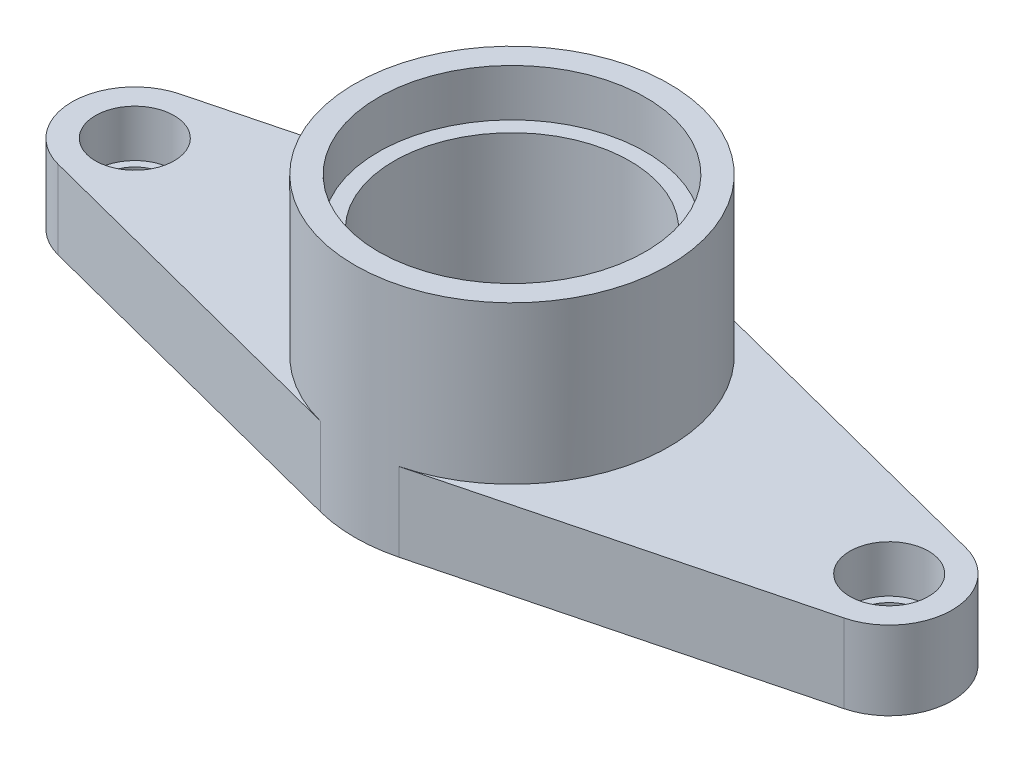
from build123d import *

# Parameters (mm, degrees)
BOSS_EXTRUDE3_DEPTH = 25
SKETCH3_R           = 10
CUT_EXTRUDE1_DEPTH  = 25
SKETCH4_R           = 12.5
CUT_EXTRUDE2_DEPTH  = 15
SKETCH5_R           = 50
BOSS_EXTRUDE5_DEPTH = 75
SKETCH9_R           = 42.5
CUT_EXTRUDE5_DEPTH  = 15
SKETCH10_R          = 37.5
CUT_EXTRUDE6_DEPTH  = 60


with BuildPart() as part:
    # Sketch2 → Boss-Extrude3 (new body)
    with BuildSketch(Plane(origin=(0, 0, 0), x_dir=(1, 0, 0), z_dir=(0, 1, 0))):
        with BuildLine():
            Line((-125, 19.364916731), (-12.5, 48.412291828))
            ThreePointArc((-12.5, 48.412291828), (0, 50), (12.5, 48.412291828))
            Line((12.5, 48.412291828), (125, 19.364916731))
            ThreePointArc((125, 19.364916731), (140, 0), (125, -19.364916731))
            Line((125, -19.364916731), (12.5, -48.412291828))
            ThreePointArc((12.5, -48.412291828), (0, -50), (-12.5, -48.412291828))
            Line((-12.5, -48.412291828), (-125, -19.364916731))
            ThreePointArc((-125, -19.364916731), (-140, 0), (-125, 19.364916731))
        make_face()
    extrude(amount=BOSS_EXTRUDE3_DEPTH)

    # Sketch3 → Cut-Extrude1 (cut)
    with BuildSketch(Plane(origin=(0, 25, 0), x_dir=(1, 0, 0), z_dir=(0, 1, 0))):
        with Locations((-120, 0)):
            Circle(SKETCH3_R)
        with Locations((120, 0)):
            Circle(SKETCH3_R)
    extrude(amount=-CUT_EXTRUDE1_DEPTH, mode=Mode.SUBTRACT)

    # Sketch4 → Cut-Extrude2 (cut)
    with BuildSketch(Plane(origin=(0, 25, 0), x_dir=(1, 0, 0), z_dir=(0, 1, 0))):
        with Locations((-120, 0)):
            Circle(SKETCH4_R)
        with Locations((120, 0)):
            Circle(SKETCH4_R)
    extrude(amount=-CUT_EXTRUDE2_DEPTH, mode=Mode.SUBTRACT)

    # Sketch5 → Boss-Extrude5 (add)
    with BuildSketch(Plane(origin=(0, 0, 0), x_dir=(1, 0, 0), z_dir=(0, 1, 0))):
        Circle(SKETCH5_R)
    extrude(amount=BOSS_EXTRUDE5_DEPTH)

    # Sketch9 → Cut-Extrude5 (cut)
    with BuildSketch(Plane(origin=(0, 75, 0), x_dir=(1, 0, 0), z_dir=(0, 1, 0))):
        Circle(SKETCH9_R)
    extrude(amount=-CUT_EXTRUDE5_DEPTH, mode=Mode.SUBTRACT)

    # Sketch10 → Cut-Extrude6 (cut)
    with BuildSketch(Plane(origin=(0, 60, 0), x_dir=(1, 0, 0), z_dir=(0, 1, 0))):
        Circle(SKETCH10_R)
    extrude(amount=-CUT_EXTRUDE6_DEPTH, mode=Mode.SUBTRACT)


solid = part.part
